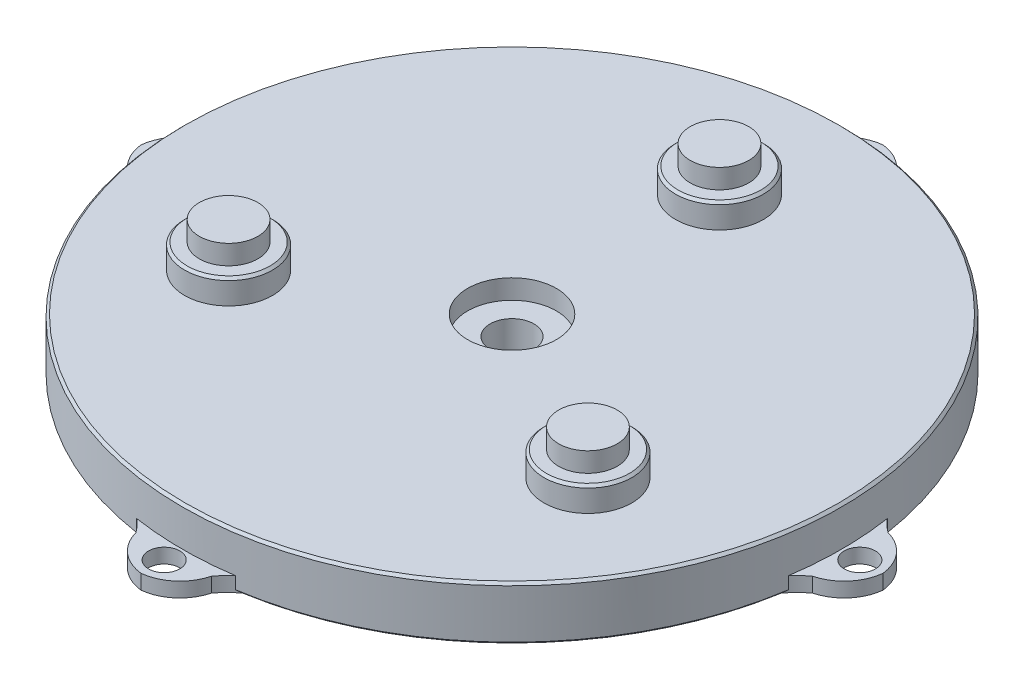
from build123d import *

# Parameters (mm, degrees)
SKETCH2_R            = 65
BOSS_EXTRUDE1_DEPTH  = 11
SKETCH3_R            = 9.1
CUT_EXTRUDE2_DEPTH   = 4
SKETCH4_R            = 4.5
CUT_EXTRUDE4_DEPTH   = 20
SKETCH5_R            = 67.5
SKETCH5_R_2          = 65
BOSS_EXTRUDE3_DEPTH  = 11
CHAMFER1_SIZE        = 0.5
CHAMFER2_SIZE        = 0.5
BOSS_EXTRUDE8_DEPTH  = 3
BOSS_EXTRUDE9_DEPTH  = 3
SKETCH8_R            = 3.2
CUT_EXTRUDE5_DEPTH   = 4
SKETCH9_R            = 9
BOSS_EXTRUDE10_DEPTH = 5
SKETCH10_R           = 6
BOSS_EXTRUDE11_DEPTH = 4
CHAMFER4_SIZE        = 0.5


with BuildPart() as part:
    # Sketch2 → Boss-Extrude1 (new body)
    with BuildSketch(Plane(origin=(0, 0, 0), x_dir=(1, 0, 0), z_dir=(0, 1, 0))):
        Circle(SKETCH2_R)
    extrude(amount=BOSS_EXTRUDE1_DEPTH)

    # Sketch3 → Cut-Extrude2 (cut)
    with BuildSketch(Plane(origin=(0, 11, 0), x_dir=(1, 0, 0), z_dir=(0, 1, 0))):
        Circle(SKETCH3_R)
    extrude(amount=-CUT_EXTRUDE2_DEPTH, mode=Mode.SUBTRACT)

    # Sketch4 → Cut-Extrude4 (cut)
    with BuildSketch(Plane(origin=(0, 7, 0), x_dir=(1, 0, 0), z_dir=(0, 1, 0))):
        Circle(SKETCH4_R)
    extrude(amount=-CUT_EXTRUDE4_DEPTH, mode=Mode.SUBTRACT)

    # Sketch5 → Boss-Extrude3 (add)
    with BuildSketch(Plane.XZ):
        Circle(SKETCH5_R)
        Circle(SKETCH5_R_2, mode=Mode.SUBTRACT)
    extrude(amount=-BOSS_EXTRUDE3_DEPTH)

    # Chamfer1
    chamfer1_edges = [part.edges().sort_by_distance(p)[0] for p in [
        (-67.5, 11, 0),
    ]]
    chamfer(chamfer1_edges, length=CHAMFER1_SIZE)

    # Chamfer2
    chamfer2_edges = [part.edges().sort_by_distance(p)[0] for p in [
        (-67.5, 0, 0),
    ]]
    chamfer(chamfer2_edges, length=CHAMFER2_SIZE)

    # Sketch6 → Boss-Extrude8 (add)
    with BuildSketch(Plane.XZ):
        with BuildLine():
            ThreePointArc((-5.99398228, 66.731343284), (-3, 66.932802123), (0, 67))
            Line((0, 67), (0, 74))
            ThreePointArc((0, 74), (-3.933906239, 72.64143706), (-6.037545702, 69.050335199))
            ThreePointArc((-6.037545702, 69.050335199), (-6.128886239, 67.888714183), (-5.99398228, 66.731343284))
        make_face()
        with BuildLine():
            Line((0, 74), (0, 67))
            ThreePointArc((0, 67), (3, 66.932802123), (5.99398228, 66.731343284))
            ThreePointArc((5.99398228, 66.731343284), (6.128886239, 67.888714183), (6.037545702, 69.050335199))
            ThreePointArc((6.037545702, 69.050335199), (3.933906239, 72.64143706), (0, 74))
        make_face()
        with BuildLine():
            ThreePointArc((6.037545702, 69.050335199), (6.128886239, 67.888714183), (5.99398228, 66.731343284))
            ThreePointArc((5.99398228, 66.731343284), (6.989304811, 66.634447685), (7.98307027, 66.522707319))
            ThreePointArc((7.98307027, 66.522707319), (6.839267191, 67.654870524), (6.037545702, 69.050335199))
        make_face()
        with BuildLine():
            ThreePointArc((-7.98307027, 66.522707319), (-6.989304811, 66.634447685), (-5.99398228, 66.731343284))
            ThreePointArc((-5.99398228, 66.731343284), (-6.128886239, 67.888714183), (-6.037545702, 69.050335199))
            ThreePointArc((-6.037545702, 69.050335199), (-6.839267191, 67.654870524), (-7.98307027, 66.522707319))
        make_face()
        with BuildLine():
            ThreePointArc((69.050335199, 6.037545702), (67.888714183, 6.128886239), (66.731343284, 5.99398228))
            ThreePointArc((66.731343284, 5.99398228), (66.932802123, 3), (67, 0))
            ThreePointArc((67, 0), (66.932802123, -3), (66.731343284, -5.99398228))
            ThreePointArc((66.731343284, -5.99398228), (67.888714183, -6.128886239), (69.050335199, -6.037545702))
            ThreePointArc((69.050335199, -6.037545702), (72.64143706, -3.933906239), (74, 0))
            ThreePointArc((74, 0), (72.64143706, 3.933906239), (69.050335199, 6.037545702))
        make_face()
        with BuildLine():
            ThreePointArc((69.050335199, 6.037545702), (67.654870524, 6.839267191), (66.522707319, 7.98307027))
            ThreePointArc((66.522707319, 7.98307027), (66.634447685, 6.989304811), (66.731343284, 5.99398228))
            ThreePointArc((66.731343284, 5.99398228), (67.888714183, 6.128886239), (69.050335199, 6.037545702))
        make_face()
        with BuildLine():
            ThreePointArc((69.050335199, -6.037545702), (67.888714183, -6.128886239), (66.731343284, -5.99398228))
            ThreePointArc((66.731343284, -5.99398228), (66.634447685, -6.989304811), (66.522707319, -7.98307027))
            ThreePointArc((66.522707319, -7.98307027), (67.654870524, -6.839267191), (69.050335199, -6.037545702))
        make_face()
        with BuildLine():
            ThreePointArc((5.99398228, -66.731343284), (0, -67), (-5.99398228, -66.731343284))
            ThreePointArc((-5.99398228, -66.731343284), (-6.128886239, -67.888714183), (-6.037545702, -69.050335199))
            ThreePointArc((-6.037545702, -69.050335199), (-3.933906239, -72.64143706), (0, -74))
            ThreePointArc((0, -74), (3.933906239, -72.64143706), (6.037545702, -69.050335199))
            ThreePointArc((6.037545702, -69.050335199), (6.128886239, -67.888714183), (5.99398228, -66.731343284))
        make_face()
        with BuildLine():
            ThreePointArc((-5.99398228, -66.731343284), (-6.989304811, -66.634447685), (-7.98307027, -66.522707319))
            ThreePointArc((-7.98307027, -66.522707319), (-6.839267191, -67.654870524), (-6.037545702, -69.050335199))
            ThreePointArc((-6.037545702, -69.050335199), (-6.128886239, -67.888714183), (-5.99398228, -66.731343284))
        make_face()
        with BuildLine():
            ThreePointArc((6.037545702, -69.050335199), (6.839267191, -67.654870524), (7.98307027, -66.522707319))
            ThreePointArc((7.98307027, -66.522707319), (6.989304811, -66.634447685), (5.99398228, -66.731343284))
            ThreePointArc((5.99398228, -66.731343284), (6.128886239, -67.888714183), (6.037545702, -69.050335199))
        make_face()
        with BuildLine():
            ThreePointArc((-66.731343284, -5.99398228), (-67, 0), (-66.731343284, 5.99398228))
            ThreePointArc((-66.731343284, 5.99398228), (-67.888714183, 6.128886239), (-69.050335199, 6.037545702))
            ThreePointArc((-69.050335199, 6.037545702), (-72.64143706, 3.933906239), (-74, 0))
            ThreePointArc((-74, 0), (-72.64143706, -3.933906239), (-69.050335199, -6.037545702))
            ThreePointArc((-69.050335199, -6.037545702), (-67.888714183, -6.128886239), (-66.731343284, -5.99398228))
        make_face()
        with BuildLine():
            ThreePointArc((-66.731343284, 5.99398228), (-66.634447685, 6.989304811), (-66.522707319, 7.98307027))
            ThreePointArc((-66.522707319, 7.98307027), (-67.654870524, 6.839267191), (-69.050335199, 6.037545702))
            ThreePointArc((-69.050335199, 6.037545702), (-67.888714183, 6.128886239), (-66.731343284, 5.99398228))
        make_face()
        with BuildLine():
            ThreePointArc((-66.522707319, -7.98307027), (-66.634447685, -6.989304811), (-66.731343284, -5.99398228))
            ThreePointArc((-66.731343284, -5.99398228), (-67.888714183, -6.128886239), (-69.050335199, -6.037545702))
            ThreePointArc((-69.050335199, -6.037545702), (-67.654870524, -6.839267191), (-66.522707319, -7.98307027))
        make_face()
    extrude(amount=-BOSS_EXTRUDE8_DEPTH)

    # Sketch7 → Boss-Extrude9 (add)
    with BuildSketch(Plane.XZ):
        with BuildLine():
            ThreePointArc((-6.037545702, 69.050335199), (-3.933906239, 72.64143706), (0, 74))
            Line((0, 74), (0, 76))
            ThreePointArc((0, 76), (-4.902011553, 73.862254638), (-7.725710636, 69.320625418))
            ThreePointArc((-7.725710636, 69.320625418), (-7.972938142, 67.9314334), (-8, 66.520673478))
            ThreePointArc((-8, 66.520673478), (-7.9915352, 66.521690937), (-7.98307027, 66.522707319))
            ThreePointArc((-7.98307027, 66.522707319), (-6.839267191, 67.654870524), (-6.037545702, 69.050335199))
        make_face()
        with BuildLine():
            Line((0, 76), (0, 74))
            ThreePointArc((0, 74), (3.933906239, 72.64143706), (6.037545702, 69.050335199))
            ThreePointArc((6.037545702, 69.050335199), (6.839267191, 67.654870524), (7.98307027, 66.522707319))
            ThreePointArc((7.98307027, 66.522707319), (7.9915352, 66.521690937), (8, 66.520673478))
            ThreePointArc((8, 66.520673478), (7.972938142, 67.9314334), (7.725710636, 69.320625418))
            ThreePointArc((7.725710636, 69.320625418), (4.902011553, 73.862254638), (0, 76))
        make_face()
        with BuildLine():
            ThreePointArc((7.725710636, 69.320625418), (7.972938142, 67.9314334), (8, 66.520673478))
            ThreePointArc((8, 66.520673478), (9.487263657, 66.324895992), (10.969771462, 66.095870628))
            ThreePointArc((10.969771462, 66.095870628), (9.215149033, 67.574862202), (7.725710636, 69.320625418))
        make_face()
        with BuildLine():
            ThreePointArc((-10.969771462, 66.095870628), (-9.487263657, 66.324895992), (-8, 66.520673478))
            ThreePointArc((-8, 66.520673478), (-7.972938142, 67.9314334), (-7.725710636, 69.320625418))
            ThreePointArc((-7.725710636, 69.320625418), (-9.215149033, 67.574862202), (-10.969771462, 66.095870628))
        make_face()
        with BuildLine():
            ThreePointArc((-66.522707319, 7.98307027), (-66.521690937, 7.9915352), (-66.520673478, 8))
            ThreePointArc((-66.520673478, 8), (-67.9314334, 7.972938142), (-69.320625418, 7.725710636))
            ThreePointArc((-69.320625418, 7.725710636), (-73.862254638, 4.902011553), (-76, 0))
            ThreePointArc((-76, 0), (-73.862254638, -4.902011553), (-69.320625418, -7.725710636))
            ThreePointArc((-69.320625418, -7.725710636), (-67.9314334, -7.972938142), (-66.520673478, -8))
            ThreePointArc((-66.520673478, -8), (-66.521690937, -7.9915352), (-66.522707319, -7.98307027))
            ThreePointArc((-66.522707319, -7.98307027), (-67.654870524, -6.839267191), (-69.050335199, -6.037545702))
            ThreePointArc((-69.050335199, -6.037545702), (-72.64143706, -3.933906239), (-74, 0))
            ThreePointArc((-74, 0), (-72.64143706, 3.933906239), (-69.050335199, 6.037545702))
            ThreePointArc((-69.050335199, 6.037545702), (-67.654870524, 6.839267191), (-66.522707319, 7.98307027))
        make_face()
        with BuildLine():
            ThreePointArc((-66.520673478, 8), (-66.324895992, 9.487263657), (-66.095870628, 10.969771462))
            ThreePointArc((-66.095870628, 10.969771462), (-67.574862202, 9.215149033), (-69.320625418, 7.725710636))
            ThreePointArc((-69.320625418, 7.725710636), (-67.9314334, 7.972938142), (-66.520673478, 8))
        make_face()
        with BuildLine():
            ThreePointArc((-66.520673478, -8), (-67.9314334, -7.972938142), (-69.320625418, -7.725710636))
            ThreePointArc((-69.320625418, -7.725710636), (-67.574862202, -9.215149033), (-66.095870628, -10.969771462))
            ThreePointArc((-66.095870628, -10.969771462), (-66.324895992, -9.487263657), (-66.520673478, -8))
        make_face()
        with BuildLine():
            ThreePointArc((-8, -66.520673478), (-9.487263657, -66.324895992), (-10.969771462, -66.095870628))
            ThreePointArc((-10.969771462, -66.095870628), (-9.215149033, -67.574862202), (-7.725710636, -69.320625418))
            ThreePointArc((-7.725710636, -69.320625418), (-7.972938142, -67.9314334), (-8, -66.520673478))
        make_face()
        with BuildLine():
            ThreePointArc((7.725710636, -69.320625418), (7.972938142, -67.9314334), (8, -66.520673478))
            ThreePointArc((8, -66.520673478), (7.9915352, -66.521690937), (7.98307027, -66.522707319))
            ThreePointArc((7.98307027, -66.522707319), (6.839267191, -67.654870524), (6.037545702, -69.050335199))
            ThreePointArc((6.037545702, -69.050335199), (3.933906239, -72.64143706), (0, -74))
            ThreePointArc((0, -74), (-3.933906239, -72.64143706), (-6.037545702, -69.050335199))
            ThreePointArc((-6.037545702, -69.050335199), (-6.839267191, -67.654870524), (-7.98307027, -66.522707319))
            ThreePointArc((-7.98307027, -66.522707319), (-7.9915352, -66.521690937), (-8, -66.520673478))
            ThreePointArc((-8, -66.520673478), (-7.972938142, -67.9314334), (-7.725710636, -69.320625418))
            ThreePointArc((-7.725710636, -69.320625418), (-4.902011553, -73.862254638), (0, -76))
            ThreePointArc((0, -76), (4.902011553, -73.862254638), (7.725710636, -69.320625418))
        make_face()
        with BuildLine():
            ThreePointArc((7.725710636, -69.320625418), (9.215149033, -67.574862202), (10.969771462, -66.095870628))
            ThreePointArc((10.969771462, -66.095870628), (9.487263657, -66.324895992), (8, -66.520673478))
            ThreePointArc((8, -66.520673478), (7.972938142, -67.9314334), (7.725710636, -69.320625418))
        make_face()
        with BuildLine():
            ThreePointArc((66.095870628, -10.969771462), (67.574862202, -9.215149033), (69.320625418, -7.725710636))
            ThreePointArc((69.320625418, -7.725710636), (67.9314334, -7.972938142), (66.520673478, -8))
            ThreePointArc((66.520673478, -8), (66.324895992, -9.487263657), (66.095870628, -10.969771462))
        make_face()
        with BuildLine():
            ThreePointArc((69.320625418, 7.725710636), (67.9314334, 7.972938142), (66.520673478, 8))
            ThreePointArc((66.520673478, 8), (66.521690937, 7.9915352), (66.522707319, 7.98307027))
            ThreePointArc((66.522707319, 7.98307027), (67.654870524, 6.839267191), (69.050335199, 6.037545702))
            ThreePointArc((69.050335199, 6.037545702), (72.64143706, 3.933906239), (74, 0))
            ThreePointArc((74, 0), (72.64143706, -3.933906239), (69.050335199, -6.037545702))
            ThreePointArc((69.050335199, -6.037545702), (67.654870524, -6.839267191), (66.522707319, -7.98307027))
            ThreePointArc((66.522707319, -7.98307027), (66.521690937, -7.9915352), (66.520673478, -8))
            ThreePointArc((66.520673478, -8), (67.9314334, -7.972938142), (69.320625418, -7.725710636))
            ThreePointArc((69.320625418, -7.725710636), (73.862254638, -4.902011553), (76, 0))
            ThreePointArc((76, 0), (73.862254638, 4.902011553), (69.320625418, 7.725710636))
        make_face()
        with BuildLine():
            ThreePointArc((69.320625418, 7.725710636), (67.574862202, 9.215149033), (66.095870628, 10.969771462))
            ThreePointArc((66.095870628, 10.969771462), (66.324895992, 9.487263657), (66.520673478, 8))
            ThreePointArc((66.520673478, 8), (67.9314334, 7.972938142), (69.320625418, 7.725710636))
        make_face()
    extrude(amount=-BOSS_EXTRUDE9_DEPTH)

    # Sketch8 → Cut-Extrude5 (cut)
    with BuildSketch(Plane.XZ):
        with Locations((0, 71.25)):
            Circle(SKETCH8_R)
        with Locations((71.25, 0)):
            Circle(SKETCH8_R)
        with Locations((0, -71.25)):
            Circle(SKETCH8_R)
        with Locations((-71.25, 0)):
            Circle(SKETCH8_R)
    extrude(amount=-CUT_EXTRUDE5_DEPTH, mode=Mode.SUBTRACT)

    # Sketch9 → Boss-Extrude10 (add)
    with BuildSketch(Plane(origin=(0, 11, 0), x_dir=(1, 0, 0), z_dir=(0, 1, 0))):
        with Locations((0, 42.5)):
            Circle(SKETCH9_R)
        with Locations((36.806079661, -21.25)):
            Circle(SKETCH9_R)
        with Locations((-36.806079661, -21.25)):
            Circle(SKETCH9_R)
    extrude(amount=BOSS_EXTRUDE10_DEPTH)

    # Sketch10 → Boss-Extrude11 (add)
    with BuildSketch(Plane(origin=(0, 16, 0), x_dir=(1, 0, 0), z_dir=(0, 1, 0))):
        with Locations((0, 42.5)):
            Circle(SKETCH10_R)
        with Locations((36.806079661, -21.25)):
            Circle(SKETCH10_R)
        with Locations((-36.806079661, -21.25)):
            Circle(SKETCH10_R)
    extrude(amount=BOSS_EXTRUDE11_DEPTH)

    # Chamfer4
    chamfer4_edges = [part.edges().sort_by_distance(p)[0] for p in [
        (-9, 16, -42.5),
        (-45.806079661, 16, 21.25),
        (27.806079661, 16, 21.25),
    ]]
    chamfer(chamfer4_edges, length=CHAMFER4_SIZE)


solid = part.part
